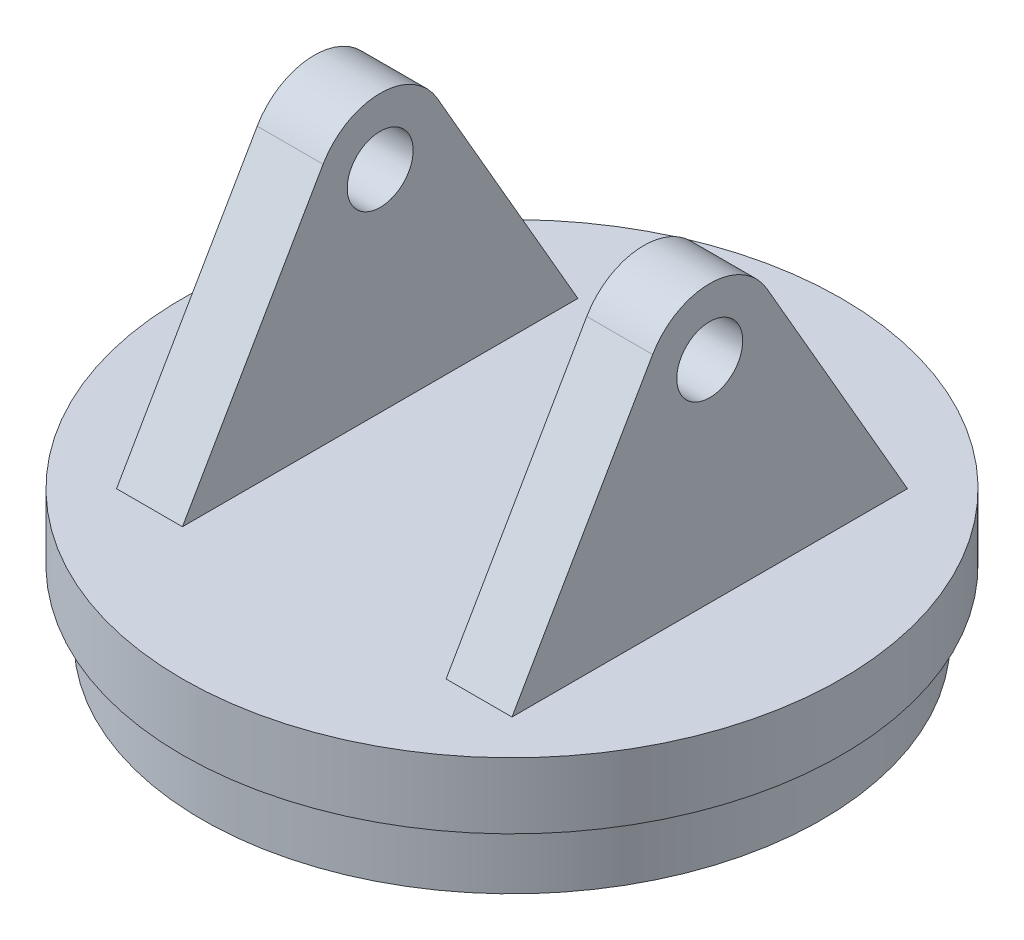
from build123d import *

# Parameters (mm, degrees)
SKETCH1_R           = 50
BOSS_EXTRUDE1_DEPTH = 10
BOSS_EXTRUDE2_START = 20
SKETCH2_R           = 5
BOSS_EXTRUDE2_DEPTH = 10
BOSS_EXTRUDE3_START = -30
SKETCH2_2_R         = 5
BOSS_EXTRUDE3_DEPTH = 10
SKETCH3_R           = 47
BOSS_EXTRUDE4_DEPTH = 10
SKETCH4_R           = 2.5
CUT_EXTRUDE1_DEPTH  = 10


with BuildPart() as part:
    # Sketch1 → Boss-Extrude1 (new body)
    with BuildSketch(Plane(origin=(0, 0, 0), x_dir=(1, 0, 0), z_dir=(0, 1, 0))):
        Circle(SKETCH1_R)
    extrude(amount=BOSS_EXTRUDE1_DEPTH)

    # Sketch2 → Boss-Extrude2 (add)
    with BuildSketch(Plane(origin=(0, 0, 0), x_dir=(0, 0, -1), z_dir=(1, 0, 0)).offset(BOSS_EXTRUDE2_START)):
        with BuildLine():
            Line((30, 10), (8.660254038, 46.961524227))
            ThreePointArc((8.660254038, 46.961524227), (0, 51.961524227), (-8.660254038, 46.961524227))
            Line((-8.660254038, 46.961524227), (-30, 10))
            Line((-30, 10), (30, 10))
        make_face()
        with Locations((0, 41.961524227)):
            Circle(SKETCH2_R, mode=Mode.SUBTRACT)
    extrude(amount=BOSS_EXTRUDE2_DEPTH)

    # Sketch2_2 → Boss-Extrude3 (add)
    with BuildSketch(Plane(origin=(0, 0, 0), x_dir=(0, 0, -1), z_dir=(1, 0, 0)).offset(BOSS_EXTRUDE3_START)):
        with BuildLine():
            Line((30, 10), (8.660254038, 46.961524227))
            ThreePointArc((8.660254038, 46.961524227), (0, 51.961524227), (-8.660254038, 46.961524227))
            Line((-8.660254038, 46.961524227), (-30, 10))
            Line((-30, 10), (30, 10))
        make_face()
        with Locations((0, 41.961524227)):
            Circle(SKETCH2_2_R, mode=Mode.SUBTRACT)
    extrude(amount=BOSS_EXTRUDE3_DEPTH)

    # Sketch3 → Boss-Extrude4 (add)
    with BuildSketch(Plane.XZ):
        Circle(SKETCH3_R)
    extrude(amount=BOSS_EXTRUDE4_DEPTH)

    # Sketch4 → Cut-Extrude1 (cut)
    with BuildSketch(Plane.XZ.offset(10)):
        Circle(SKETCH4_R)
    extrude(amount=-CUT_EXTRUDE1_DEPTH, mode=Mode.SUBTRACT)


solid = part.part
